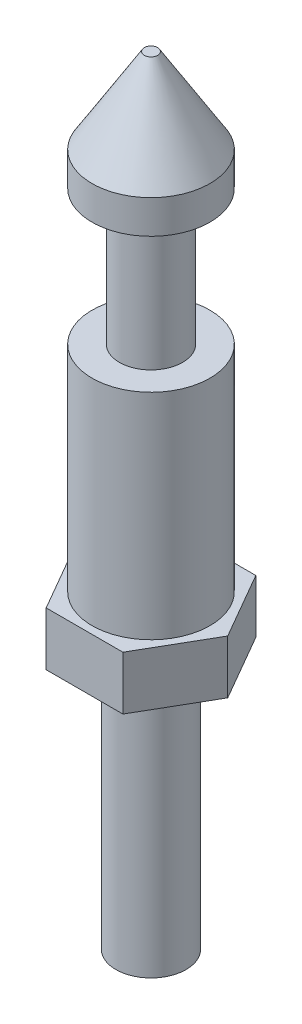
from build123d import *

# Parameters (mm, degrees)
BOSS_EXTRUDE1_DEPTH = 2.54


with BuildPart() as part:
    # Sketch1 → Revolve1 (revolve)
    with BuildSketch(Plane.XY, mode=Mode.PRIVATE) as revolve1_sk:
        Polygon((0, 0), (1.6637, 0), (1.6637, 12.1412), (2.794, 12.1412), (2.794, 24.8412), (1.4986, 24.8412), (1.4986, 31.242), (2.794, 31.242), (2.794, 32.8295), (0.3175, 36.8554), (0, 36.8554), align=None)
    revolve(revolve1_sk.sketch.rotate(Axis((0, 0, 0), (0, 1, 0)), 90), axis=Axis((0, 0, 0), (0, 1, 0)))  # turned: the seam where the file's is

    # Sketch2 → Boss-Extrude1 (add)
    with BuildSketch(Plane.XZ.offset(-12.1412)):
        Polygon((3.636844816, 0), (1.818422408, 3.1496), (-1.818422408, 3.1496), (-3.636844816, 0), (-1.818422408, -3.1496), (1.818422408, -3.1496), align=None)
    extrude(amount=-BOSS_EXTRUDE1_DEPTH)


solid = part.part
